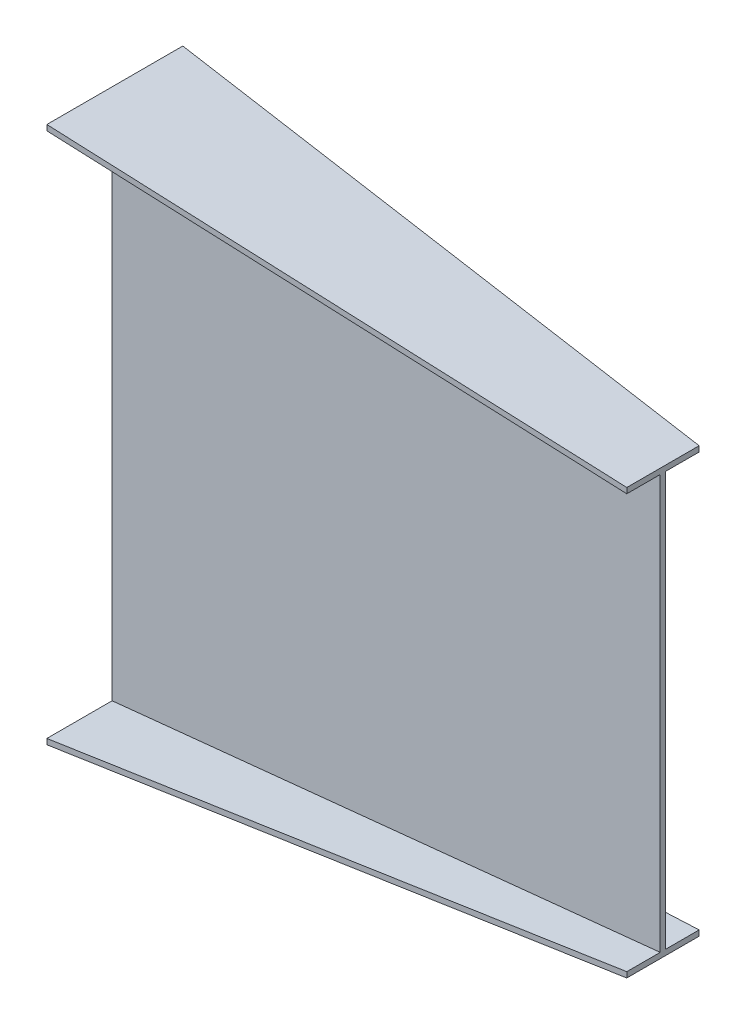
from build123d import *


with BuildPart() as part:
    # Sketch1 → Loft l3 section 0
    with BuildSketch(Plane(origin=(0, 0, 0), x_dir=(0, 0, -1), z_dir=(1, 0, 0))):
        Polygon((-129, 490), (119, 490), (119, 480), (0, 480), (0, -480), (119, -480), (119, -490), (-129, -490), (-129, -480), (-10, -480), (-10, 480), (-129, 480), align=None)
    # Sketch4 → Loft l3 section 1
    with BuildSketch(Plane(origin=(1000, 0, -1000), x_dir=(0, 0, 1), z_dir=(-1, 0, 0))):
        Polygon((939, 387.5), (1071, 387.5), (1071, 377.5), (1010, 377.5), (1010, -377.5), (1071, -377.5), (1071, -387.5), (939, -387.5), (939, -377.5), (1000, -377.5), (1000, 377.5), (939, 377.5), align=None)
    loft()


solid = part.part
